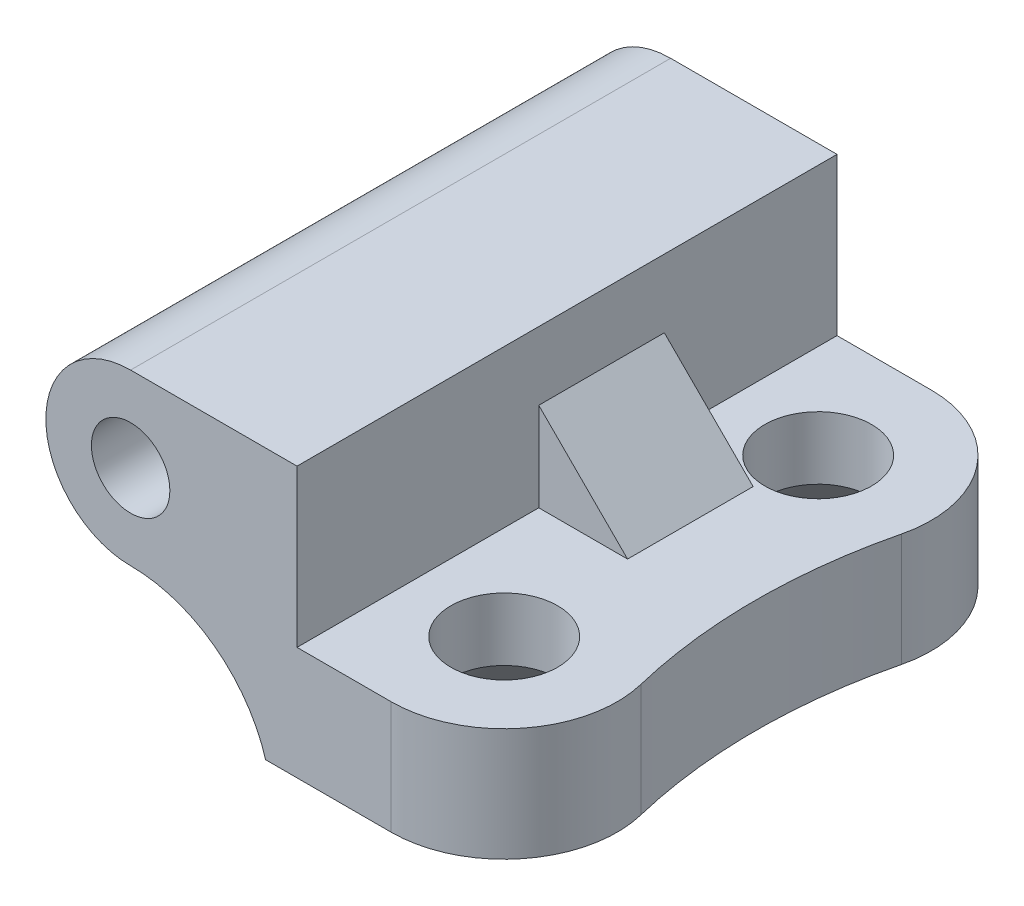
from build123d import *

# Parameters (mm, degrees)
SKETCH_1_R                = 1.25
EXTRUDE_1_DEPTH           = 17.2
CUT_EXTRUDE_1_DEPTH       = 9.6
EXTRUDE_2_DEPTH           = 4
HOLE_WIZARD_1_D           = 3.4
HOLE_WIZARD_1_DEPTH       = 8.6
HOLE_WIZARD_1_CSINK_D     = 6.6
HOLE_WIZARD_1_CSINK_ANGLE = 90
HOLE_WIZARD_1_TIP         = 1.021463052


with BuildPart() as part:
    # 草图1 → 凸台-拉伸1 (new body)
    with BuildSketch(Plane.XY):
        with BuildLine():
            Line((0, 2.7), (5.3, 2.7))
            Line((5.3, 2.7), (5.3, -2.3))
            Line((5.3, -2.3), (12.8, -2.3))
            Line((12.8, -2.3), (12.8, -5.9))
            Line((12.8, -5.9), (4.3, -5.9))
            ThreePointArc((4.3, -5.9), (2.680018657, -3.58778743), (0, -2.7))
            ThreePointArc((0, -2.7), (-2.7, 0), (0, 2.7))
        make_face()
        Circle(SKETCH_1_R, mode=Mode.SUBTRACT)
    extrude(amount=EXTRUDE_1_DEPTH)

    # 草图6 → 切除-拉伸1 (cut, through all)
    with BuildSketch(Plane.XZ.offset(5.9)):
        with BuildLine():
            Line((8.3, 0), (12.8, 0))
            Line((12.8, 0), (12.8, 17.2))
            Line((12.8, 17.2), (8.3, 17.2))
            ThreePointArc((8.3, 17.2), (10.845584412, 16.145584412), (11.9, 13.6))
            ThreePointArc((11.9, 13.6), (11.874356619, 13.171077206), (11.797791798, 12.748264984))
            ThreePointArc((11.797791798, 12.748264984), (11.3, 8.6), (11.797791798, 4.451735016))
            ThreePointArc((11.797791798, 4.451735016), (11.874356619, 4.028922794), (11.9, 3.6))
            ThreePointArc((11.9, 3.6), (10.845584412, 1.054415588), (8.3, 0))
        make_face()
    extrude(amount=-CUT_EXTRUDE_1_DEPTH, mode=Mode.SUBTRACT)

    # 草图7 → 凸台-拉伸2 (add)
    with BuildSketch(Plane.XY.offset(5.5)):
        Polygon((8.128427125, -2.3), (5.3, -2.3), (5.3, 0.528427125), align=None)
    extrude(amount=EXTRUDE_2_DEPTH)

    # 打孔尺寸(%根据)开槽半沉头木螺钉的类型1
    with Locations(Plane(origin=(8.3, -5.9, 3.6), x_dir=(-1, 0, 0), z_dir=(0, -1, 0))):
        with Locations((0, 0), (0, -10)):
            CounterSinkHole(HOLE_WIZARD_1_D / 2, HOLE_WIZARD_1_CSINK_D / 2, depth=HOLE_WIZARD_1_DEPTH, counter_sink_angle=HOLE_WIZARD_1_CSINK_ANGLE)
            with Locations((0, 0, -(HOLE_WIZARD_1_DEPTH + HOLE_WIZARD_1_TIP / 2))):  # 118° drill point
                Cone(0, HOLE_WIZARD_1_D / 2, HOLE_WIZARD_1_TIP, mode=Mode.SUBTRACT)


solid = part.part
